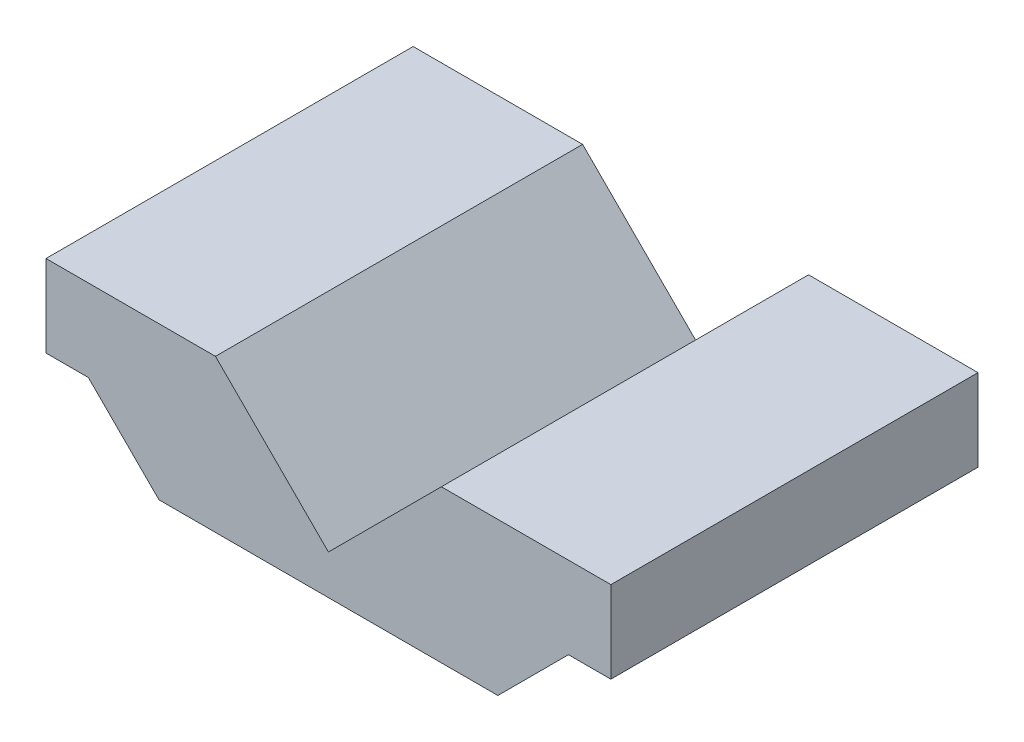
from build123d import *

# Parameters (mm, degrees)
BOSS_EXTRUDE1_DEPTH            = 32.5
TALADRO_ROSCADO_M86_AT_2_COUNT = 2
TALADRO_ROSCADO_M86_AT_2_PITCH = 40


with BuildPart() as part:
    # Sketch1 → Boss-Extrude1 (new body, symmetric)
    with BuildSketch(Plane.XY):
        Polygon((-30, 0), (30, 0), (42.5, 12.5), (50, 12.5), (50, 27), (20, 27), (0, 7), (-20, 27), (-50, 27), (-50, 12.5), (-42.5, 12.5), align=None)
    extrude(amount=BOSS_EXTRUDE1_DEPTH, both=True)

    # Croquis12 → Taladro roscado M86 (revolve, cut)
    with BuildSketch(Plane(origin=(33.725048023, 3.725048023, 20), x_dir=(0.707106781, 0.707106781, 0), z_dir=(0, 0, 1))):
        Polygon((0, 0), (0, 22.042926105), (3.4, 20), (3.4, 0), align=None)
    taladro_roscado_m86 = revolve(axis=Axis((38.215176084, -0.765080037, 20), (-0.707106781, 0.707106781, 0)), mode=Mode.SUBTRACT)

    # Taladro roscado M86 at 2: Taladro roscado M86 ×2
    with Locations(*[(0, 0, -i * TALADRO_ROSCADO_M86_AT_2_PITCH) for i in range(1, TALADRO_ROSCADO_M86_AT_2_COUNT)]):
        add(taladro_roscado_m86, mode=Mode.SUBTRACT)

    # Simetría3: Taladro roscado M86 across plane
    add(taladro_roscado_m86.mirror(Plane(origin=(0, 0, 0), x_dir=(0, 0, 1), z_dir=(1, 0, 0))), mode=Mode.SUBTRACT)

    # Simetría3 copy 1 sketch → Simetría3 copy 1 (revolve, cut)
    with BuildSketch(Plane(origin=(-33.725048023, 3.725048023, -20), x_dir=(-0.707106781, 0.707106781, 0), z_dir=(0, 0, 1))):
        Polygon((0, 0), (0, -22.042926105), (3.4, -20), (3.4, 0), align=None)
    revolve(axis=Axis((-38.215176084, -0.765080037, -20), (-0.707106781, -0.707106781, 0)), mode=Mode.SUBTRACT)


solid = part.part
